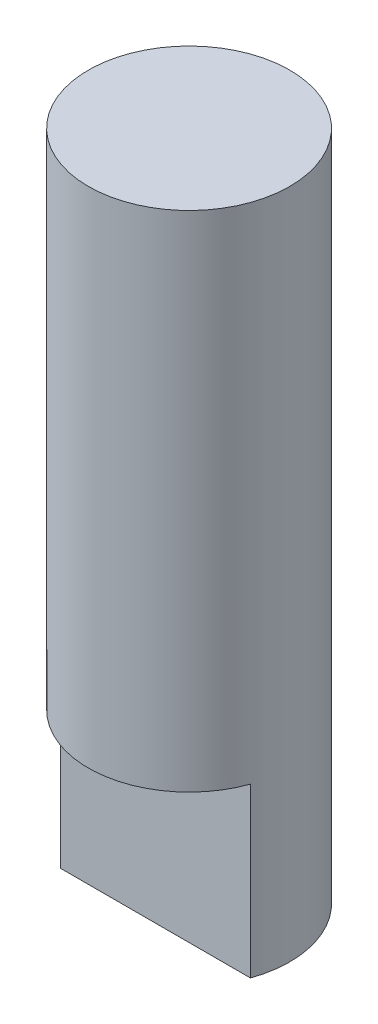
from build123d import *

# Parameters (mm, degrees)
SKETCH1_R           = 3
BOSS_EXTRUDE1_DEPTH = 20
CUT_EXTRUDE1_DEPTH  = 5


with BuildPart() as part:
    # Sketch1 → Boss-Extrude1 (new body)
    with BuildSketch(Plane(origin=(0, 0, 0), x_dir=(1, 0, 0), z_dir=(0, 1, 0))):
        Circle(SKETCH1_R)
    extrude(amount=BOSS_EXTRUDE1_DEPTH)

    # Sketch2 → Cut-Extrude1 (cut)
    with BuildSketch(Plane.XZ):
        with BuildLine():
            Line((-2.828427125, 1), (2.828427125, 1))
            ThreePointArc((2.828427125, 1), (0, 3), (-2.828427125, 1))
        make_face()
    extrude(amount=-CUT_EXTRUDE1_DEPTH, mode=Mode.SUBTRACT)


solid = part.part
